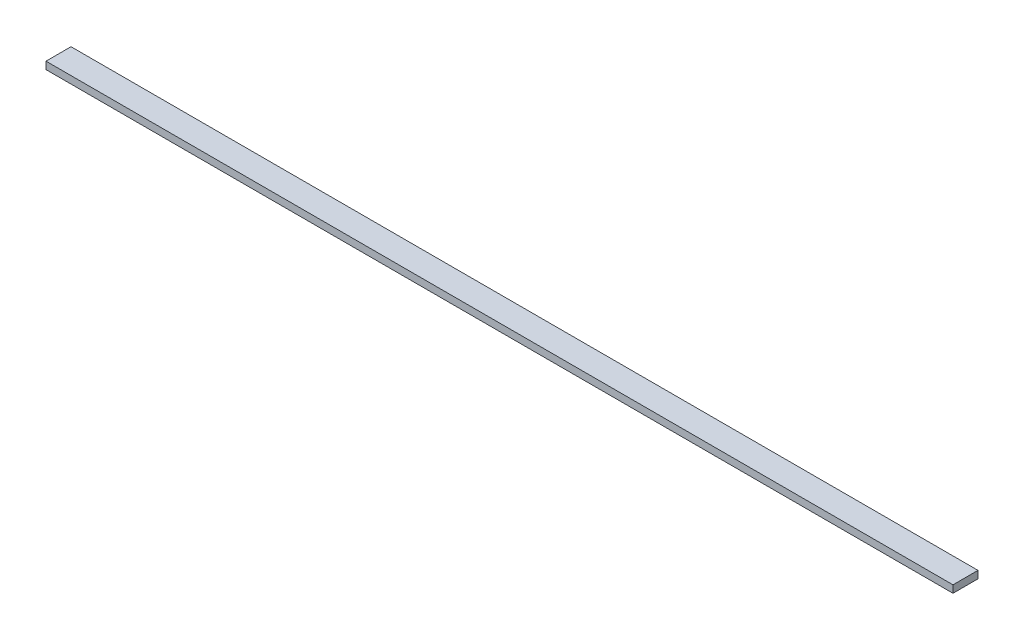
from build123d import *

# Parameters (mm, degrees)
SKETCH3_W           = 123.25
SKETCH3_H           = 3.4
BOSS_EXTRUDE3_DEPTH = 0.5


with BuildPart() as part:
    # Sketch3 → Boss-Extrude3 (new body, symmetric)
    with BuildSketch(Plane(origin=(0, 0, 0), x_dir=(1, 0, 0), z_dir=(0, 1, 0))):
        Rectangle(SKETCH3_W, SKETCH3_H)
    extrude(amount=BOSS_EXTRUDE3_DEPTH, both=True)


solid = part.part
